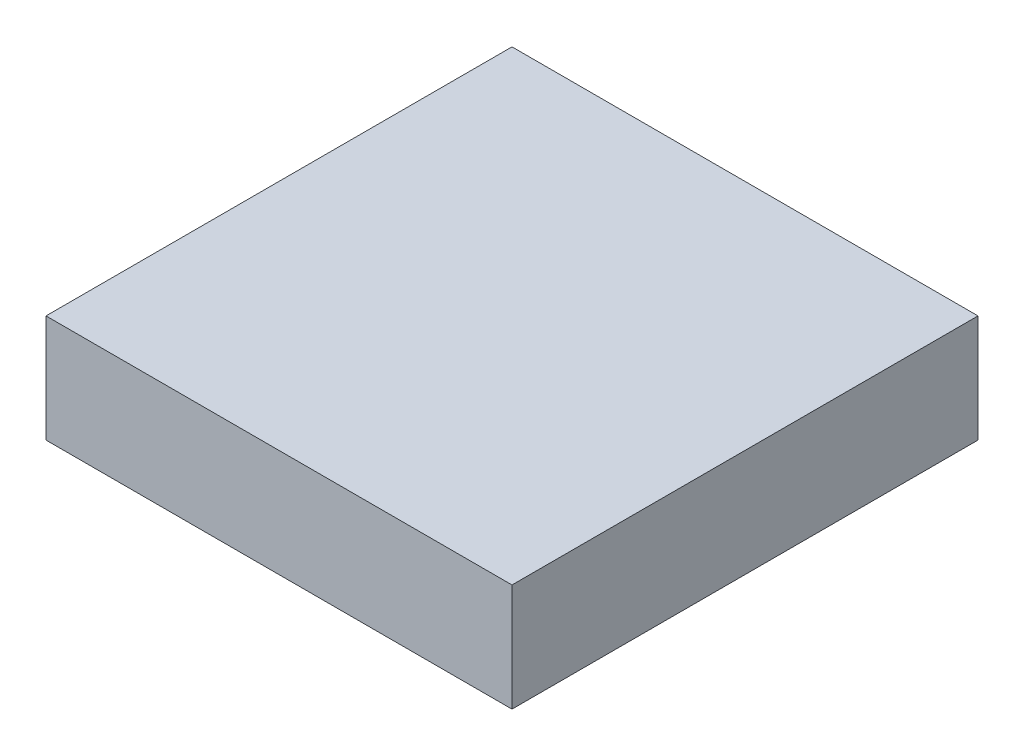
from build123d import *

# Parameters (mm, degrees)
SKETCH1_W           = 120
SKETCH1_H           = 120
BOSS_EXTRUDE1_DEPTH = 27.7


with BuildPart() as part:
    # Sketch1 → Boss-Extrude1 (new body)
    with BuildSketch(Plane(origin=(0, 0, 0), x_dir=(1, 0, 0), z_dir=(0, 1, 0))):
        with Locations((60, 60)):
            Rectangle(SKETCH1_W, SKETCH1_H)
    extrude(amount=BOSS_EXTRUDE1_DEPTH)


solid = part.part
